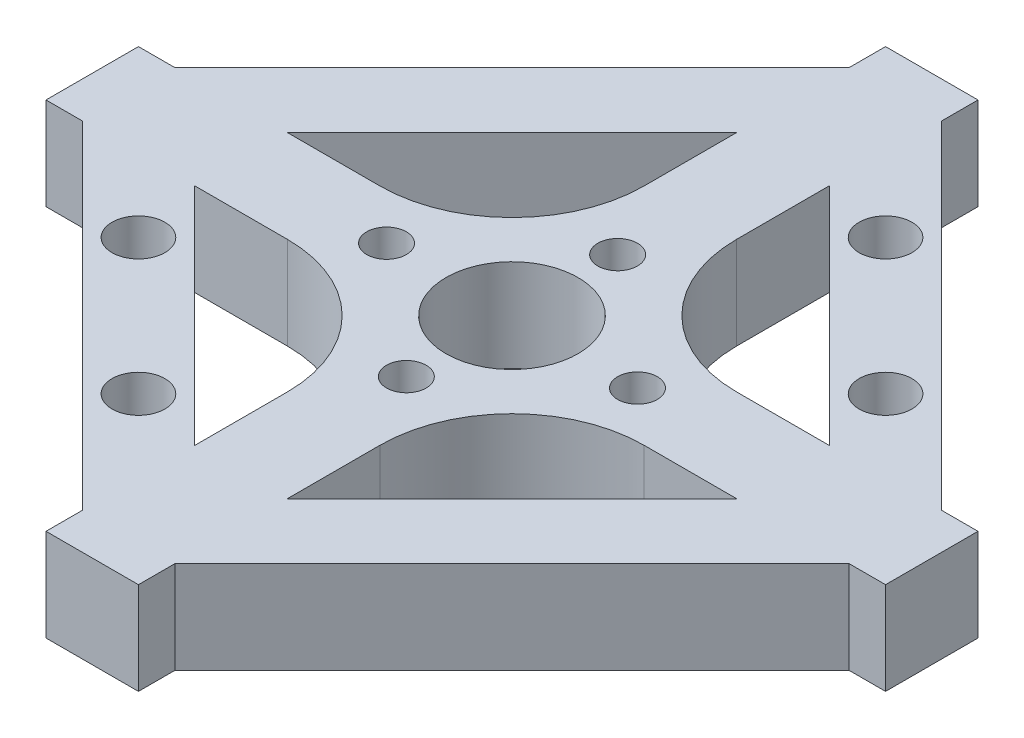
from build123d import *

# Parameters (mm, degrees)
SKETCH1_R           = 1.5
BOSS_EXTRUDE1_DEPTH = 7


with BuildPart() as part:
    # Sketch1 → Boss-Extrude1 (new body)
    with BuildSketch(Plane(origin=(0, 0, 0), x_dir=(1, 0, 0), z_dir=(0, 1, 0))):
        Polygon((-3.5, -29.026911935), (-3.5, -31.784271247), (3.5, -31.784271247), (3.5, -29.026911935), (29.026911935, -3.5), (31.784271247, -3.5), (31.784271247, 3.5), (29.026911935, 3.5), (3.5, 29.026911935), (3.5, 31.784271247), (-3.5, 31.784271247), (-3.5, 29.026911935), (-29.026911935, 3.5), (-31.784271247, 3.5), (-31.784271247, 0.742640687), (-31.784271247, -3.5), (-29.026911935, -3.5), align=None)
        with BuildLine():
            ThreePointArc((-7.01561146, -19.268659787), (-7.167852395, -20.034026652), (-7.601397898, -20.68287335))
            ThreePointArc((-7.601397898, -20.68287335), (-10.429825023, -20.68287335), (-10.429825023, -17.854446225))
            ThreePointArc((-10.429825023, -17.854446225), (-8.250244595, -17.420900722), (-7.01561146, -19.268659787))
        make_face(mode=Mode.SUBTRACT)
        with BuildLine():
            ThreePointArc((-17.854446225, -10.429825023), (-20.68287335, -10.429825023), (-20.68287335, -7.601397898))
            ThreePointArc((-20.68287335, -7.601397898), (-18.503292923, -7.167852395), (-17.268659787, -9.01561146))
            ThreePointArc((-17.268659787, -9.01561146), (-17.420900722, -9.780978325), (-17.854446225, -10.429825023))
        make_face(mode=Mode.SUBTRACT)
        with BuildLine():
            Line((-3.5, -13.5), (-3.5, -20.54163056))
            Line((-3.5, -20.54163056), (-20.54163056, -3.5))
            Line((-20.54163056, -3.5), (-13.5, -3.5))
            ThreePointArc((-13.5, -3.5), (-6.428932188, -6.428932188), (-3.5, -13.5))
        make_face(mode=Mode.SUBTRACT)
        with Locations((0, -8)):
            Circle(SKETCH1_R, mode=Mode.SUBTRACT)
        with BuildLine():
            ThreePointArc((3.5, -13.5), (6.428932188, -6.428932188), (13.5, -3.5))
            Line((13.5, -3.5), (20.54163056, -3.5))
            Line((20.54163056, -3.5), (3.5, -20.54163056))
            Line((3.5, -20.54163056), (3.5, -13.5))
        make_face(mode=Mode.SUBTRACT)
        with Locations((-9.5, 0)):
            Circle(SKETCH1_R, mode=Mode.SUBTRACT)
        with BuildLine():
            Line((-20.54163056, 3.5), (-3.5, 20.54163056))
            Line((-3.5, 20.54163056), (-3.5, 13.5))
            ThreePointArc((-3.5, 13.5), (-4.261204675, 9.673165676), (-6.428932188, 6.428932188))
            ThreePointArc((-6.428932188, 6.428932188), (-9.673165676, 4.261204675), (-13.5, 3.5))
            Line((-13.5, 3.5), (-20.54163056, 3.5))
        make_face(mode=Mode.SUBTRACT)
        with BuildLine():
            ThreePointArc((3.570714214, 3.5), (4.628907596, 1.890294809), (5, 0))
            ThreePointArc((5, 0), (4.628907596, -1.890294809), (3.570714214, -3.5))
            ThreePointArc((3.570714214, -3.5), (3.535533906, -3.535533906), (3.5, -3.570714214))
            ThreePointArc((3.5, -3.570714214), (0, -5), (-3.5, -3.570714214))
            ThreePointArc((-3.5, -3.570714214), (-3.535533906, -3.535533906), (-3.570714214, -3.5))
            ThreePointArc((-3.570714214, -3.5), (-5, 0), (-3.570714214, 3.5))
            ThreePointArc((-3.570714214, 3.5), (-3.553168481, 3.517810931), (-3.535533906, 3.535533906))
            ThreePointArc((-3.535533906, 3.535533906), (-3.517810931, 3.553168481), (-3.5, 3.570714214))
            ThreePointArc((-3.5, 3.570714214), (-1.890294809, 4.628907596), (0, 5))
            ThreePointArc((0, 5), (1.890294809, 4.628907596), (3.5, 3.570714214))
            ThreePointArc((3.5, 3.570714214), (3.517810931, 3.553168481), (3.535533906, 3.535533906))
            ThreePointArc((3.535533906, 3.535533906), (3.553168481, 3.517810931), (3.570714214, 3.5))
        make_face(mode=Mode.SUBTRACT)
        with BuildLine():
            ThreePointArc((11, 0), (9.5, -1.5), (8, 0))
            ThreePointArc((8, 0), (9.5, 1.5), (11, 0))
        make_face(mode=Mode.SUBTRACT)
        with BuildLine():
            ThreePointArc((0, 6.5), (-1.060660172, 9.060660172), (1.5, 8))
            ThreePointArc((1.5, 8), (1.060660172, 6.939339828), (0, 6.5))
        make_face(mode=Mode.SUBTRACT)
        with BuildLine():
            ThreePointArc((13.5, 3.5), (9.673165676, 4.261204675), (6.428932188, 6.428932188))
            ThreePointArc((6.428932188, 6.428932188), (4.261204675, 9.673165676), (3.5, 13.5))
            Line((3.5, 13.5), (3.5, 20.54163056))
            Line((3.5, 20.54163056), (12.02081528, 12.02081528))
            Line((12.02081528, 12.02081528), (20.54163056, 3.5))
            Line((20.54163056, 3.5), (13.5, 3.5))
        make_face(mode=Mode.SUBTRACT)
        with BuildLine():
            ThreePointArc((20.68287335, 7.601397898), (17.854446225, 7.601397898), (17.854446225, 10.429825023))
            ThreePointArc((17.854446225, 10.429825023), (20.034026652, 10.863370525), (21.268659787, 9.01561146))
            ThreePointArc((21.268659787, 9.01561146), (21.116418852, 8.250244595), (20.68287335, 7.601397898))
        make_face(mode=Mode.SUBTRACT)
        with BuildLine():
            ThreePointArc((10.429825023, 17.854446225), (7.601397898, 17.854446225), (7.601397898, 20.68287335))
            ThreePointArc((7.601397898, 20.68287335), (9.780978325, 21.116418852), (11.01561146, 19.268659787))
            ThreePointArc((11.01561146, 19.268659787), (10.863370525, 18.503292923), (10.429825023, 17.854446225))
        make_face(mode=Mode.SUBTRACT)
    extrude(amount=BOSS_EXTRUDE1_DEPTH)


solid = part.part
